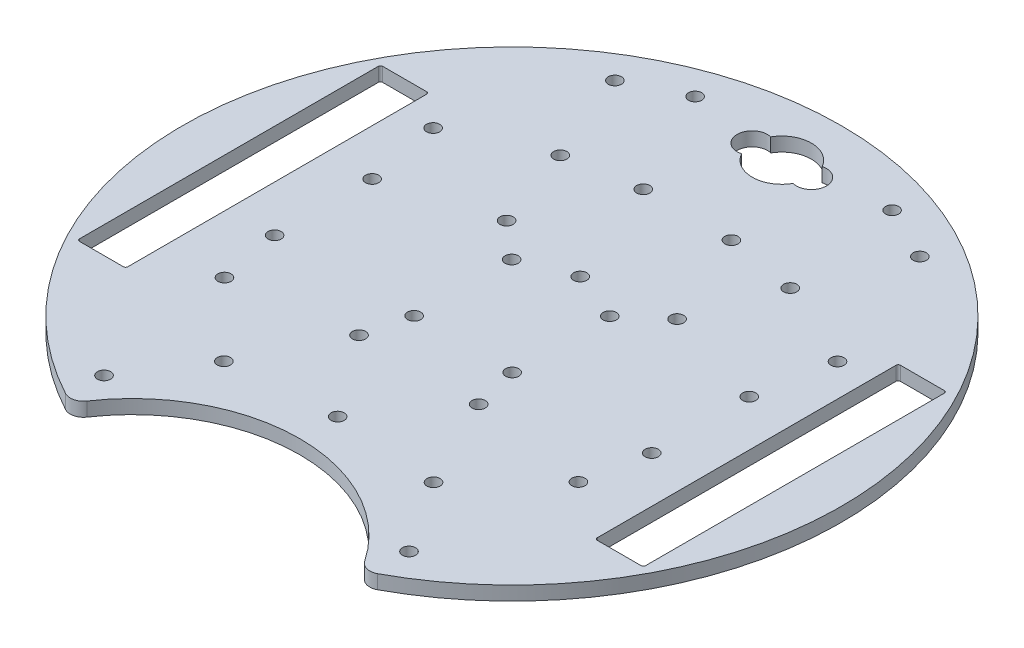
from build123d import *

# Parameters (mm, degrees)
SKETCH1_R           = 1.5
BOSS_EXTRUDE2_DEPTH = 3.175


with BuildPart() as part:
    # Sketch1 → Boss-Extrude2 (new body)
    with BuildSketch(Plane(origin=(0, 0, 0), x_dir=(1, 0, 0), z_dir=(0, 1, 0))):
        with BuildLine():
            ThreePointArc((35.49727084, -66.067721036), (0, 75), (-35.49727084, -66.067721036))
            ThreePointArc((-35.49727084, -66.067721036), (-33.357679643, -66.33740492), (-31.589980006, -65.102164912))
            ThreePointArc((-31.589980006, -65.102164912), (0, -48.302004425), (31.589980006, -65.102164912))
            ThreePointArc((31.589980006, -65.102164912), (33.357679643, -66.33740492), (35.49727084, -66.067721036))
        make_face()
        with Locations((-13.608916499, -21.183093811)):
            Circle(SKETCH1_R, mode=Mode.SUBTRACT)
        with Locations((-46.011477091, 28.075890486)):
            Circle(SKETCH1_R, mode=Mode.SUBTRACT)
        with Locations((13.608916499, -21.183093811)):
            Circle(SKETCH1_R, mode=Mode.SUBTRACT)
        with Locations((23.852486199, -41.694616163)):
            Circle(SKETCH1_R, mode=Mode.SUBTRACT)
        with Locations((-42.910067426, 11.1)):
            Circle(SKETCH1_R, mode=Mode.SUBTRACT)
        with Locations((-42.910067426, -11.1)):
            Circle(SKETCH1_R, mode=Mode.SUBTRACT)
        with Locations((-11.160067426, -11.1)):
            Circle(SKETCH1_R, mode=Mode.SUBTRACT)
        with Locations((-11.160067426, 11.1)):
            Circle(SKETCH1_R, mode=Mode.SUBTRACT)
        with Locations((11.160067426, 11.1)):
            Circle(SKETCH1_R, mode=Mode.SUBTRACT)
        with Locations((11.160067426, -11.1)):
            Circle(SKETCH1_R, mode=Mode.SUBTRACT)
        with Locations((42.910067426, -11.1)):
            Circle(SKETCH1_R, mode=Mode.SUBTRACT)
        with Locations((42.910067426, 11.1)):
            Circle(SKETCH1_R, mode=Mode.SUBTRACT)
        with Locations((-23.852486199, -41.694616163)):
            Circle(SKETCH1_R, mode=Mode.SUBTRACT)
        with Locations((19.397913834, 18.186588214)):
            Circle(SKETCH1_R, mode=Mode.SUBTRACT)
        with Locations((-40.277379234, -25.14022965)):
            Circle(SKETCH1_R, mode=Mode.SUBTRACT)
        with Locations((40.277379234, -25.14022965)):
            Circle(SKETCH1_R, mode=Mode.SUBTRACT)
        with Locations((-22.416161975, 64.096715224)):
            Circle(SKETCH1_R, mode=Mode.SUBTRACT)
        with Locations((22.416161975, 64.096715224)):
            Circle(SKETCH1_R, mode=Mode.SUBTRACT)
        with Locations((26.163250867, 37.1696126)):
            Circle(SKETCH1_R, mode=Mode.SUBTRACT)
        with Locations((46.011477091, 28.075890486)):
            Circle(SKETCH1_R, mode=Mode.SUBTRACT)
        with Locations((10.027203595, 39.91869143)):
            Circle(SKETCH1_R, mode=Mode.SUBTRACT)
        with Locations((0, -39.659190322)):
            Circle(SKETCH1_R, mode=Mode.SUBTRACT)
        with Locations((-10.027203595, 39.91869143)):
            Circle(SKETCH1_R, mode=Mode.SUBTRACT)
        with Locations((-34.69516474, -58.122990171)):
            Circle(SKETCH1_R, mode=Mode.SUBTRACT)
        with Locations((-34.69516474, 58.122990171)):
            Circle(SKETCH1_R, mode=Mode.SUBTRACT)
        with Locations((34.69516474, -58.122990171)):
            Circle(SKETCH1_R, mode=Mode.SUBTRACT)
        with Locations((0, 15.543589551)):
            Circle(SKETCH1_R, mode=Mode.SUBTRACT)
        with Locations((-26.163250867, 37.1696126)):
            Circle(SKETCH1_R, mode=Mode.SUBTRACT)
        with Locations((-19.397913834, 18.186588214)):
            Circle(SKETCH1_R, mode=Mode.SUBTRACT)
        with Locations((34.69516474, 58.122990171)):
            Circle(SKETCH1_R, mode=Mode.SUBTRACT)
        with BuildLine():
            Line((53.410067426, -34), (53.410067426, 34))
            ThreePointArc((53.410067426, 34), (53.556514035, 34.353553391), (53.910067426, 34.5))
            Line((53.910067426, 34.5), (63.910067426, 34.5))
            ThreePointArc((63.910067426, 34.5), (64.263620817, 34.353553391), (64.410067426, 34))
            Line((64.410067426, 34), (64.410067426, -34))
            ThreePointArc((64.410067426, -34), (64.263620817, -34.353553391), (63.910067426, -34.5))
            Line((63.910067426, -34.5), (53.910067426, -34.5))
            ThreePointArc((53.910067426, -34.5), (53.556514035, -34.353553391), (53.410067426, -34))
        make_face(mode=Mode.SUBTRACT)
        with BuildLine():
            Line((-63.910067426, -34.5), (-53.910067426, -34.5))
            ThreePointArc((-53.910067426, -34.5), (-53.556514035, -34.353553391), (-53.410067426, -34))
            Line((-53.410067426, -34), (-53.410067426, 34))
            ThreePointArc((-53.410067426, 34), (-53.556514035, 34.353553391), (-53.910067426, 34.5))
            Line((-53.910067426, 34.5), (-63.910067426, 34.5))
            ThreePointArc((-63.910067426, 34.5), (-64.263620817, 34.353553391), (-64.410067426, 34))
            Line((-64.410067426, 34), (-64.410067426, -34))
            ThreePointArc((-64.410067426, -34), (-64.263620817, -34.353553391), (-63.910067426, -34.5))
        make_face(mode=Mode.SUBTRACT)
        with BuildLine():
            ThreePointArc((-5.853899988, 64.744946271), (0.003726822, 68.153564176), (5.857575472, 64.738461857))
            ThreePointArc((5.857575472, 64.738461857), (10.16, 61.422565207), (5.857575472, 58.106668557))
            ThreePointArc((5.857575472, 58.106668557), (0.003726822, 54.691566239), (-5.853899988, 58.100184144))
            ThreePointArc((-5.853899988, 58.100184144), (-10.167207264, 61.422565207), (-5.853899988, 64.744946271))
        make_face(mode=Mode.SUBTRACT)
    extrude(amount=BOSS_EXTRUDE2_DEPTH)


solid = part.part
